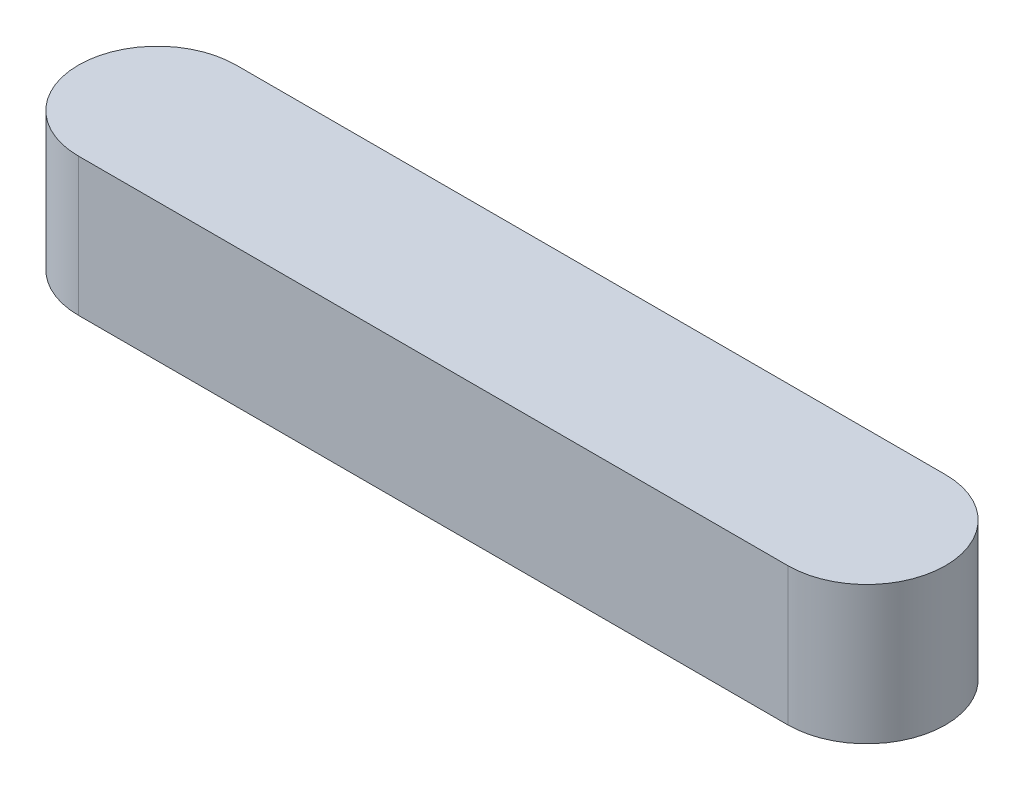
from build123d import *

# Parameters (mm, degrees)
BOSS_EXTRUDE1_DEPTH = 3.5


with BuildPart() as part:
    # Sketch1 → Boss-Extrude1 (new body)
    with BuildSketch(Plane(origin=(0, 0, 0), x_dir=(1, 0, 0), z_dir=(0, 1, 0))):
        with BuildLine():
            Line((-9, 2), (9, 2))
            ThreePointArc((9, 2), (11, 0), (9, -2))
            Line((9, -2), (-9, -2))
            ThreePointArc((-9, -2), (-11, 0), (-9, 2))
        make_face()
    extrude(amount=BOSS_EXTRUDE1_DEPTH)


solid = part.part
